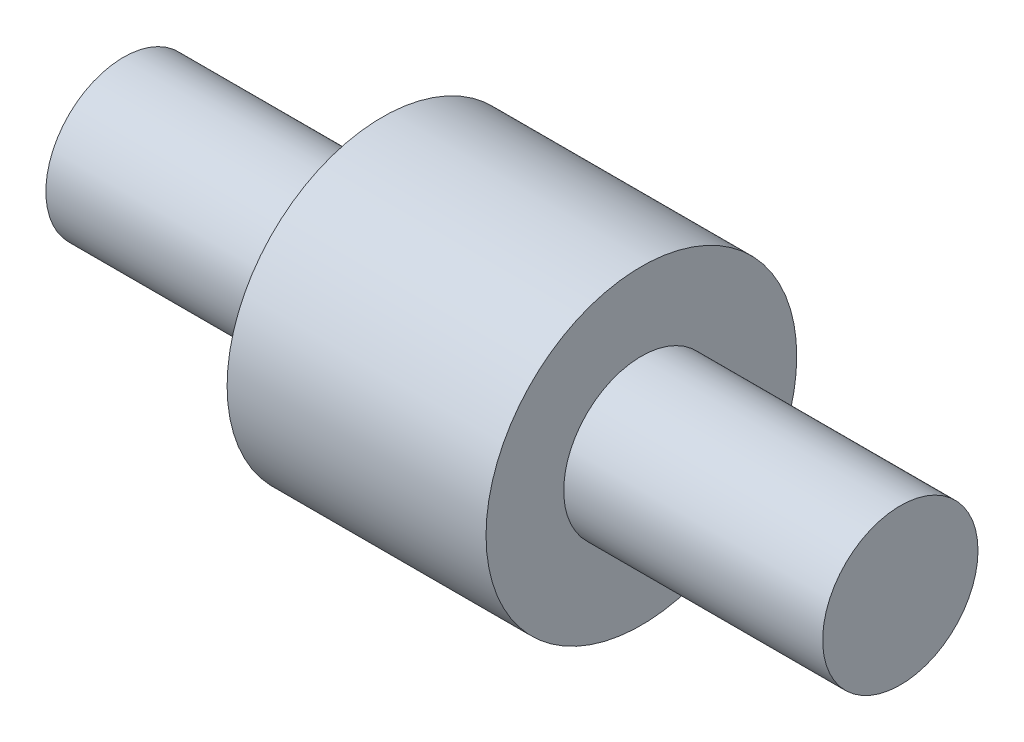
from build123d import *


with BuildPart() as part:
    # Esquisse1 → Révolution1 (revolve)
    with BuildSketch(Plane.XY, mode=Mode.PRIVATE) as r_volution1_sk:
        Polygon((0, 0), (0, 1.5), (5, 1.5), (5, 3), (10, 3), (10, 1.5), (15, 1.5), (15, 0), align=None)
    revolve(r_volution1_sk.sketch.rotate(Axis((15, 0, 0), (-1, 0, 0)), 90), axis=Axis((15, 0, 0), (-1, 0, 0)))  # turned: the seam where the file's is


solid = part.part
